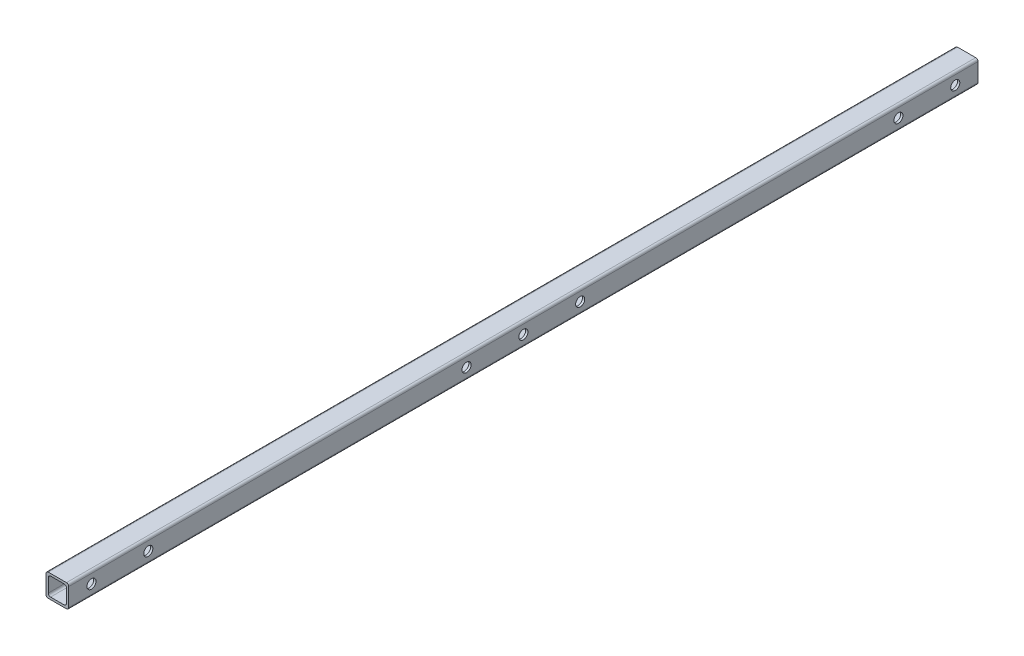
from build123d import *

# Parameters (mm, degrees)
SKETCH1_W           = 10
SKETCH1_H           = 10
SKETCH1_W_2         = 8
SKETCH1_H_2         = 8
BOSS_EXTRUDE1_DEPTH = 400
FILLET1_R           = 1
SKETCH2_R           = 2
CUT_EXTRUDE1_DEPTH  = 27


with BuildPart() as part:
    # Sketch1 → Boss-Extrude1 (new body)
    with BuildSketch(Plane.XY):
        with Locations((5, 5)):
            Rectangle(SKETCH1_W, SKETCH1_H)
        with Locations((5, 5)):
            Rectangle(SKETCH1_W_2, SKETCH1_H_2, mode=Mode.SUBTRACT)
    extrude(amount=-BOSS_EXTRUDE1_DEPTH)

    # Fillet1
    fillet1_edges = [part.edges().sort_by_distance(p)[0] for p in [
        (1, 1, -200),
        (1, 9, -200),
        (9, 9, -200),
        (9, 1, -200),
        (0, 10, -200),
        (10, 10, -200),
        (10, 0, -200),
        (0, 0, -200),
    ]]
    fillet(fillet1_edges, radius=FILLET1_R)

    # Sketch2 → Cut-Extrude1 (cut)
    with BuildSketch(Plane(origin=(10, 0, 0), x_dir=(0, 0, -1), z_dir=(1, 0, 0))):
        with Locations((200, 5)):
            Circle(SKETCH2_R)
        with Locations((225, 5)):
            Circle(SKETCH2_R)
        with Locations((175, 5)):
            Circle(SKETCH2_R)
        with Locations((10, 5)):
            Circle(SKETCH2_R)
        with Locations((35, 5)):
            Circle(SKETCH2_R)
        with Locations((390, 5)):
            Circle(SKETCH2_R)
        with Locations((365, 5)):
            Circle(SKETCH2_R)
    extrude(amount=-CUT_EXTRUDE1_DEPTH, mode=Mode.SUBTRACT)


solid = part.part
